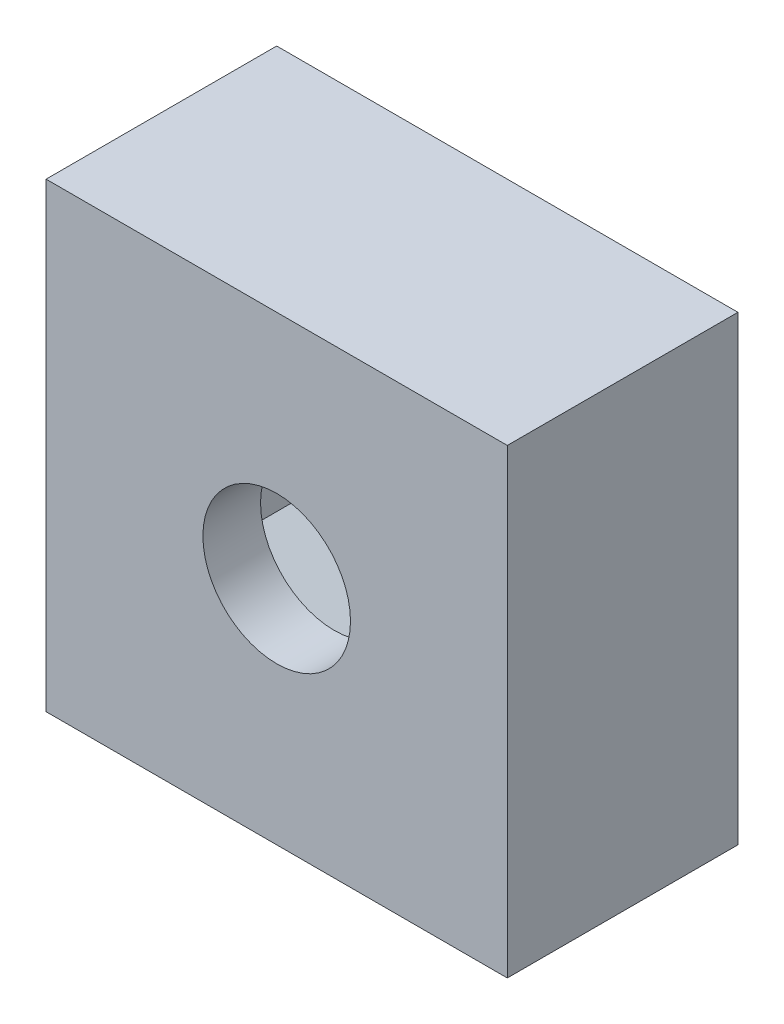
from build123d import *

# Parameters (mm, degrees)
SKETCH1_W           = 10
SKETCH1_H           = 10
BOSS_EXTRUDE1_DEPTH = 5
CUT_EXTRUDE1_START  = 1.25
CUT_EXTRUDE1_DEPTH  = 2.5
SKETCH2_R           = 1.6
CUT_EXTRUDE2_DEPTH  = 9.660254038


with BuildPart() as part:
    # Sketch1 → Boss-Extrude1 (new body)
    with BuildSketch(Plane.XY):
        Rectangle(SKETCH1_W, SKETCH1_H)
    extrude(amount=BOSS_EXTRUDE1_DEPTH)

    # Sketch1_3 → Cut-Extrude1 (cut)
    with BuildSketch(Plane.XY.offset(CUT_EXTRUDE1_START)):
        Polygon((2.975, 1.717617051), (0, 3.435234102), (-2.975, 1.717617051), (-2.975, -1.717617051), (0, -3.435234102), (2.975, -1.717617051), align=None)
    extrude(amount=CUT_EXTRUDE1_DEPTH, mode=Mode.SUBTRACT)

    # Sketch2 → Cut-Extrude2 (cut, through all)
    with BuildSketch(Plane.XY.offset(5)):
        Circle(SKETCH2_R)
    extrude(amount=-CUT_EXTRUDE2_DEPTH, mode=Mode.SUBTRACT)


solid = part.part
